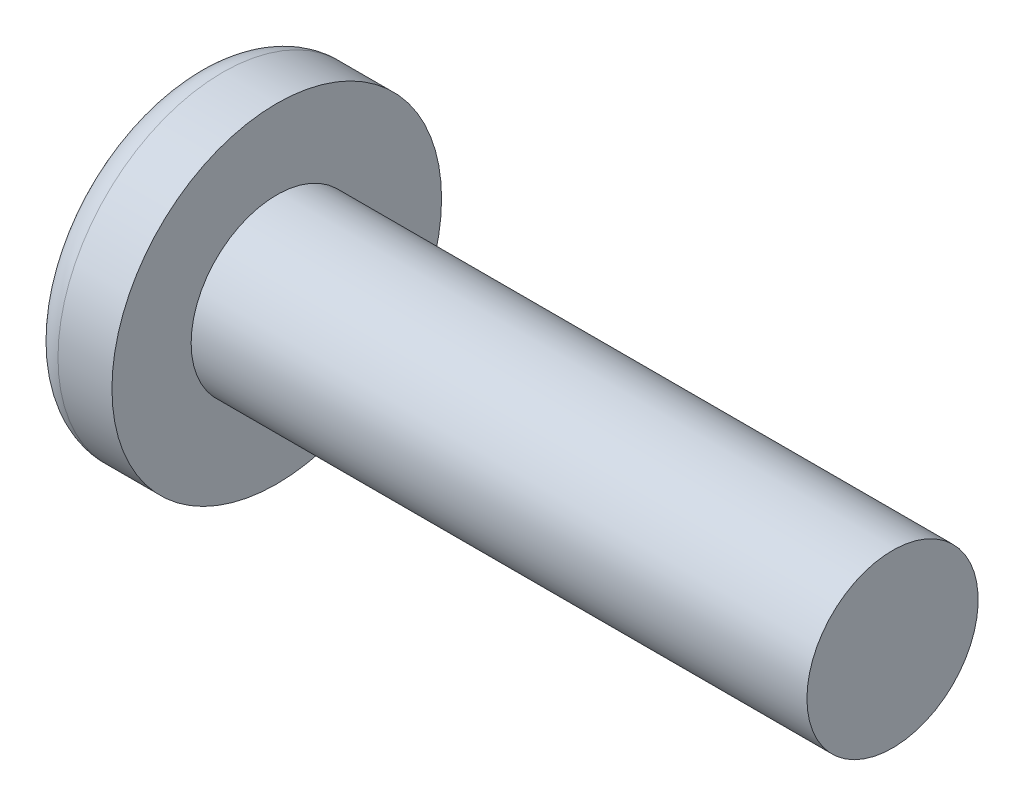
from build123d import *

# Parameters (mm, degrees)
SKETCH3_W         = 0.74
SKETCH3_H         = 2.9
SKETCH4_W         = 0.37
SKETCH4_H         = 0.37
CIRPATTERN1_COUNT = 2
CIRPATTERN1_ANGLE = 90


with BuildPart() as part:
    # BodySke → Base-Revolve (revolve)
    with BuildSketch(Plane.XY):
        with BuildLine():
            Line((1.35, 1.065), (1.35, 2.05))
            Line((1.35, 2.05), (0.678715469, 2.05))
            ThreePointArc((0.678715469, 2.05), (0.475741885, 1.987324274), (0.343443393, 1.82112069))
            ThreePointArc((0.343443393, 1.82112069), (0.086610995, 0.92661129), (0, 0))
            Line((0, 0), (9.01, 0))
            Line((9.01, 0), (9.01, 1.065))
            Line((9.01, 1.065), (1.35, 1.065))
        make_face()
    revolve(axis=Axis((-25.4, 0, 0), (1, 0, 0)))

    # Sketch3 → Cut-Loft1 section 0
    with BuildSketch(Plane(origin=(0, 0, 0), x_dir=(0, 0, -1), z_dir=(1, 0, 0))):
        Rectangle(SKETCH3_W, SKETCH3_H)
    # Sketch4 → Cut-Loft1 section 1
    with BuildSketch(Plane(origin=(1.76, 0, 0), x_dir=(0, 0, -1), z_dir=(1, 0, 0))):
        Rectangle(SKETCH4_W, SKETCH4_H)
    cut_loft1 = loft(mode=Mode.SUBTRACT)

    # CirPattern1: Cut-Loft1 ×2 about axis
    cirpattern1_axis = Axis((0, 0, 0), (1, 0, 0))
    for i in range(1, CIRPATTERN1_COUNT):
        add(cut_loft1.rotate(cirpattern1_axis, i * CIRPATTERN1_ANGLE / (CIRPATTERN1_COUNT - 1)), mode=Mode.SUBTRACT)


solid = part.part
